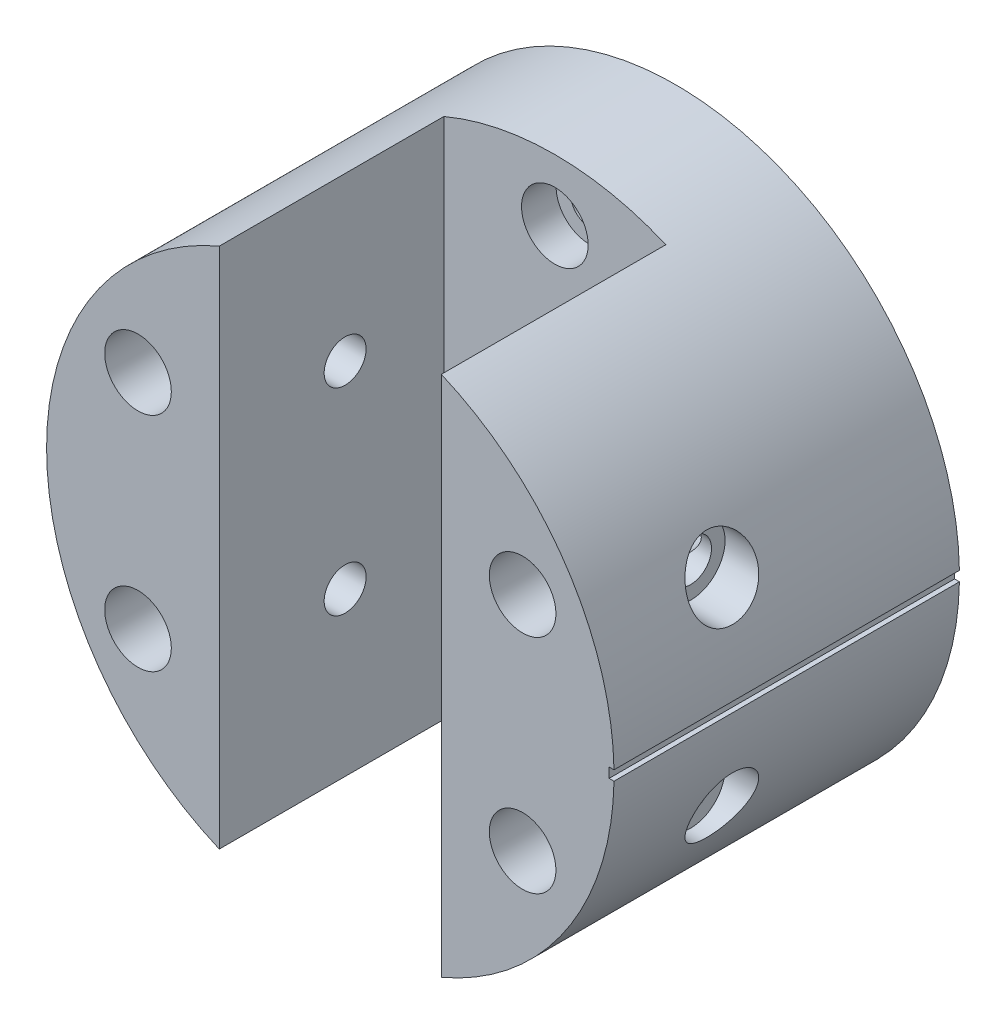
from build123d import *

# Parameters (mm, degrees)
SKETCH_1_R               = 23
EXTRUDE_1_DEPTH          = 28
CUT_EXTRUDE_1_DEPTH      = 18.2
SKETCH_3_R               = 1.5
CUT_EXTRUDE_2_DEPTH      = 29
SKETCH_5_R               = 2.7
CUT_EXTRUDE_3_DEPTH      = 21
SKETCH_7_R               = 1.7
CUT_EXTRUDE_4_DEPTH      = 33
CUT_EXTRUDE_4_DEPTH_BACK = 15
SKETCH_8_R               = 2.8
CUT_EXTRUDE_5_DEPTH      = 4
SKETCH_9_W               = 62.31985428
SKETCH_9_H               = 0.8
CUT_EXTRUDE_6_DEPTH      = 0.4


with BuildPart() as part:
    # 草图1 → 凸台-拉伸1 (new body)
    with BuildSketch(Plane.XY):
        Circle(SKETCH_1_R)
    extrude(amount=EXTRUDE_1_DEPTH)

    # 草图2 → 切除-拉伸1 (cut)
    with BuildSketch(Plane.XY.offset(28)):
        with BuildLine():
            ThreePointArc((9, 21.166010489), (0, 23), (-9, 21.166010489))
            Line((-9, 21.166010489), (-9, -21.166010489))
            ThreePointArc((-9, -21.166010489), (0, -23), (9, -21.166010489))
            Line((9, -21.166010489), (9, 21.166010489))
        make_face()
    extrude(amount=-CUT_EXTRUDE_1_DEPTH, mode=Mode.SUBTRACT)

    # 草图3 → 切除-拉伸2 (cut, through all)
    with BuildSketch(Plane.XY.offset(28)):
        with Locations((0, 18)):
            Circle(SKETCH_3_R)
        with Locations((15.588457268, 9)):
            Circle(SKETCH_3_R)
        with Locations((15.588457268, -9)):
            Circle(SKETCH_3_R)
        with Locations((0, -18)):
            Circle(SKETCH_3_R)
        with Locations((-15.588457268, -9)):
            Circle(SKETCH_3_R)
        with Locations((-15.588457268, 9)):
            Circle(SKETCH_3_R)
    extrude(amount=-CUT_EXTRUDE_2_DEPTH, mode=Mode.SUBTRACT)

    # 草图5 → 切除-拉伸3 (cut)
    with BuildSketch(Plane.XY.offset(28)):
        with Locations((0, 18)):
            Circle(SKETCH_5_R)
        with Locations((15.588457268, 9)):
            Circle(SKETCH_5_R)
        with Locations((15.588457268, -9)):
            Circle(SKETCH_5_R)
        with Locations((0, -18)):
            Circle(SKETCH_5_R)
        with Locations((-15.588457268, -9)):
            Circle(SKETCH_5_R)
        with Locations((-15.588457268, 9)):
            Circle(SKETCH_5_R)
    extrude(amount=-CUT_EXTRUDE_3_DEPTH, mode=Mode.SUBTRACT)

    # 草图7 → 切除-拉伸4 (cut, two sides)
    with BuildSketch(Plane.ZY.offset(-9)) as cut_extrude_4_sk:
        with Locations((17.8, 8)):
            Circle(SKETCH_7_R)
        with Locations((17.8, -8)):
            Circle(SKETCH_7_R)
    extrude(amount=CUT_EXTRUDE_4_DEPTH, mode=Mode.SUBTRACT)
    extrude(cut_extrude_4_sk.sketch, amount=-CUT_EXTRUDE_4_DEPTH_BACK, mode=Mode.SUBTRACT)

    # 草图8 → 切除-拉伸5 (cut)
    with BuildSketch(Plane.ZY.offset(-23)):
        with Locations((17.8, 8)):
            Circle(SKETCH_8_R)
        with Locations((17.8, -8)):
            Circle(SKETCH_8_R)
    extrude(amount=CUT_EXTRUDE_5_DEPTH, mode=Mode.SUBTRACT)

    # 草图9 → 切除-拉伸6 (cut)
    with BuildSketch(Plane.ZY.offset(-23)):
        Rectangle(SKETCH_9_W, SKETCH_9_H)
    extrude(amount=CUT_EXTRUDE_6_DEPTH, mode=Mode.SUBTRACT)


solid = part.part
